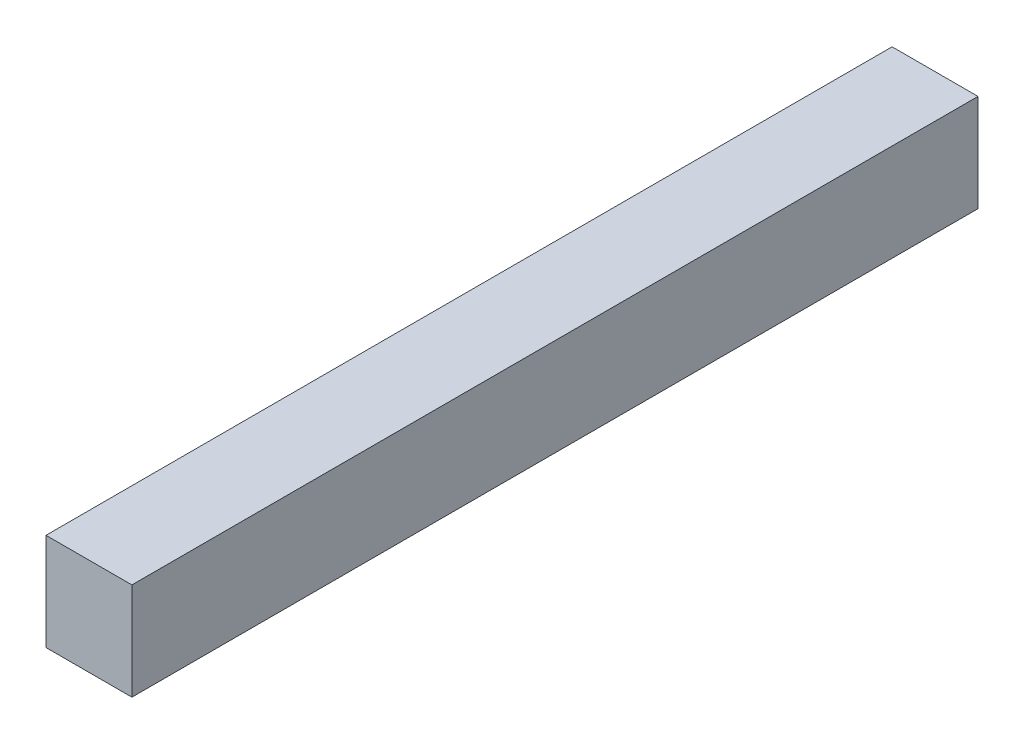
from build123d import *

# Parameters (mm, degrees)
BATTERY_PACK_CROSS_SECTION_W = 134.62
BATTERY_PACK_CROSS_SECTION_H = 152.4
BATTERY_PACK_DEPTH           = 662.94


with BuildPart() as part:
    # Battery Pack Cross Section → Battery Pack (new body, symmetric)
    with BuildSketch(Plane.XY):
        Rectangle(BATTERY_PACK_CROSS_SECTION_W, BATTERY_PACK_CROSS_SECTION_H)
    extrude(amount=BATTERY_PACK_DEPTH, both=True)


solid = part.part
